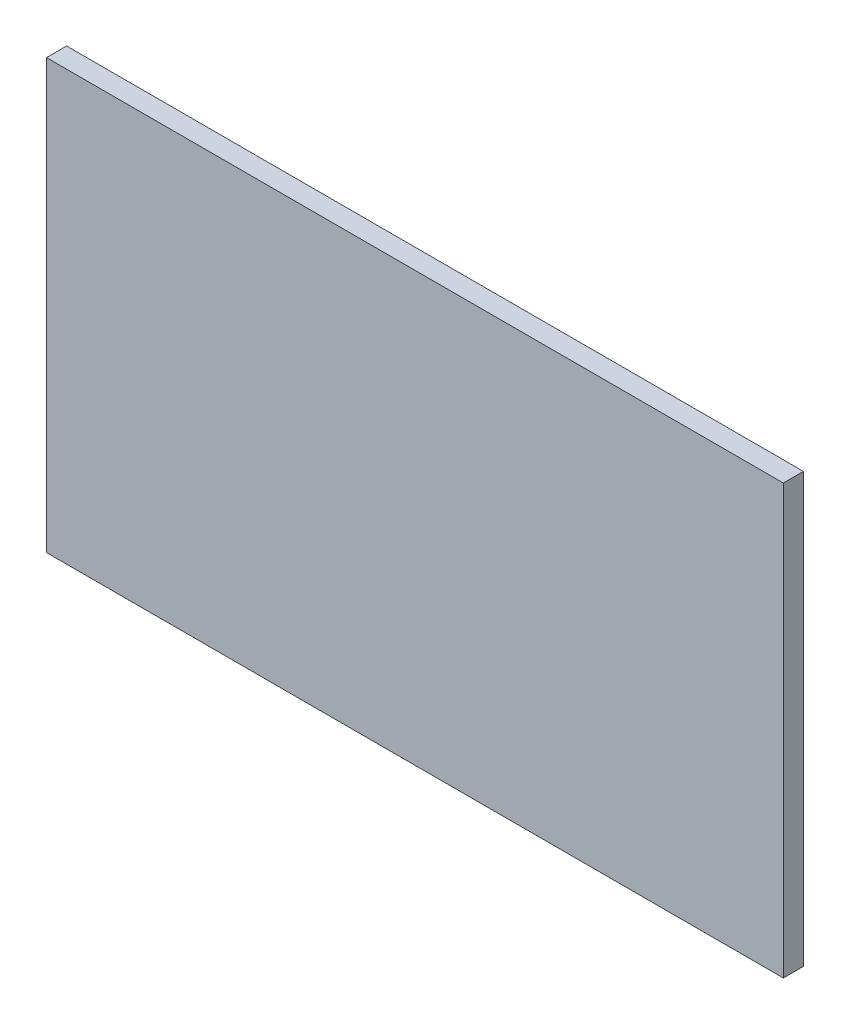
from build123d import *

# Parameters (mm, degrees)
SKETCH_1_W      = 110
SKETCH_1_H      = 64
EXTRUDE_1_DEPTH = 3


with BuildPart() as part:
    # 草图1 → 凸台-拉伸1 (new body)
    with BuildSketch(Plane.XY):
        with Locations((55, -32)):
            Rectangle(SKETCH_1_W, SKETCH_1_H)
    extrude(amount=EXTRUDE_1_DEPTH)


solid = part.part
